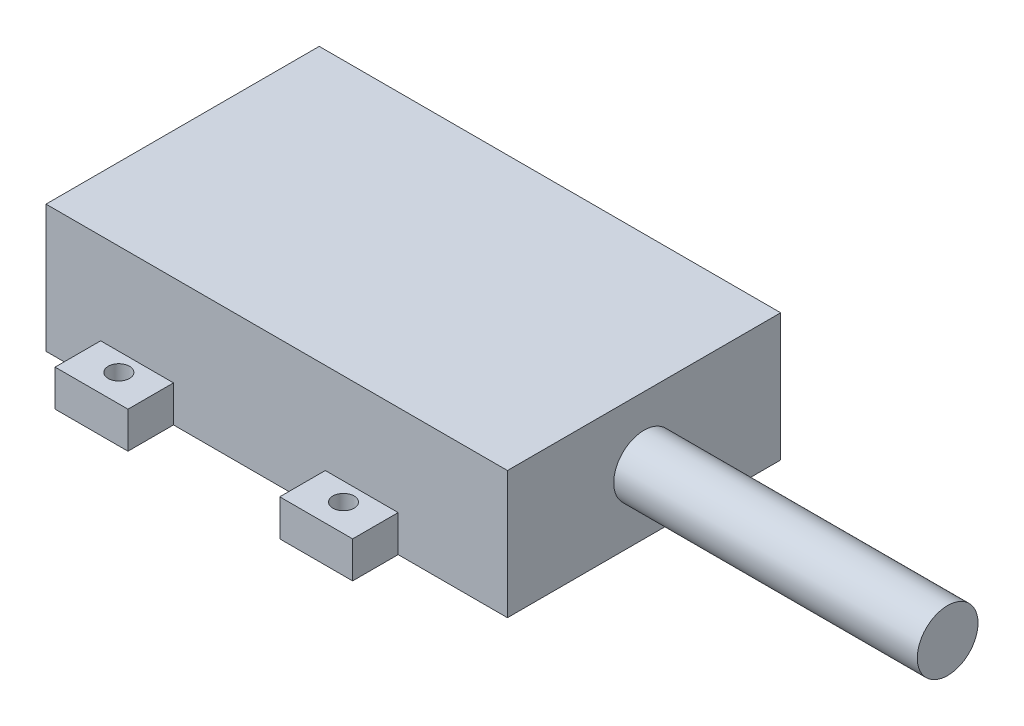
from build123d import *

# Parameters (mm, degrees)
SKETCH_1_W      = 76
SKETCH_1_H      = 45
EXTRUDE_1_DEPTH = 21
SKETCH_2_W      = 12
SKETCH_2_H      = 15
SKETCH_2_R      = 1.75
EXTRUDE_2_DEPTH = 6
SKETCH_3_R      = 5
EXTRUDE_3_DEPTH = 50


with BuildPart() as part:
    # 草图1 → 凸台-拉伸1 (new body)
    with BuildSketch(Plane(origin=(0, 0, 0), x_dir=(1, 0, 0), z_dir=(0, 1, 0))):
        Rectangle(SKETCH_1_W, SKETCH_1_H)
    extrude(amount=EXTRUDE_1_DEPTH)

    # 草图2 → 凸台-拉伸2 (add)
    with BuildSketch(Plane(origin=(0, 0, 0), x_dir=(1, 0, 0), z_dir=(0, 1, 0))):
        with Locations((-23, -22.5)):
            Rectangle(SKETCH_2_W, SKETCH_2_H)
        with Locations((-23, -25.5)):
            Circle(SKETCH_2_R, mode=Mode.SUBTRACT)
        with Locations((14, -22.5)):
            Rectangle(SKETCH_2_W, SKETCH_2_H)
        with Locations((14, -25.5)):
            Circle(SKETCH_2_R, mode=Mode.SUBTRACT)
        with Locations((14, 22.5)):
            Rectangle(SKETCH_2_W, SKETCH_2_H)
        with Locations((14, 25.5)):
            Circle(SKETCH_2_R, mode=Mode.SUBTRACT)
        with Locations((-23, 22.5)):
            Rectangle(SKETCH_2_W, SKETCH_2_H)
        with Locations((-23, 25.5)):
            Circle(SKETCH_2_R, mode=Mode.SUBTRACT)
    extrude(amount=EXTRUDE_2_DEPTH)

    # 草图3 → 凸台-拉伸3 (add)
    with BuildSketch(Plane(origin=(38, 0, 0), x_dir=(0, 0, -1), z_dir=(1, 0, 0))):
        with Locations((0, 10.5)):
            Circle(SKETCH_3_R)
    extrude(amount=EXTRUDE_3_DEPTH)


solid = part.part
